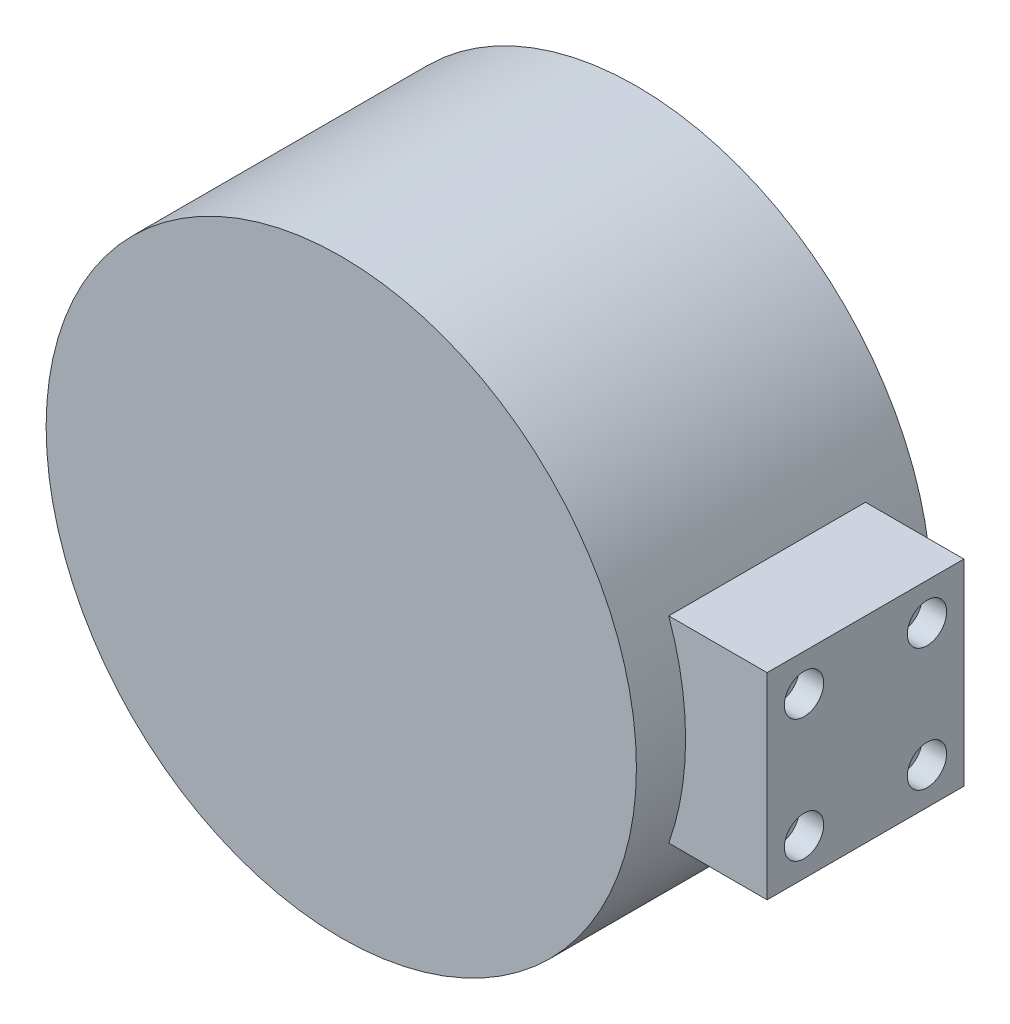
from build123d import *

# Parameters (mm, degrees)
EXTRUDE_1_DEPTH     = 60
CUT_EXTRUDE_1_DEPTH = 10
CUT_EXTRUDE_2_DEPTH = 10
SKETCH_4_R          = 40
CUT_EXTRUDE_3_DEPTH = 20
SKETCH_5_R          = 4
CUT_EXTRUDE_4_DEPTH = 5


with BuildPart() as part:
    # 草图1 → 凸台-拉伸1 (new body)
    with BuildSketch(Plane.XY):
        with BuildLine():
            Line((56.568542495, -20), (76.568542495, -20))
            Line((76.568542495, -20), (76.568542495, 20))
            Line((76.568542495, 20), (56.568542495, 20))
            ThreePointArc((56.568542495, 20), (-60, 0), (56.568542495, -20))
        make_face()
    extrude(amount=EXTRUDE_1_DEPTH)

    # 草图2 → 切除-拉伸1 (cut)
    with BuildSketch(Plane(origin=(0, 0, 0), x_dir=(-1, 0, 0), z_dir=(0, 0, -1))):
        with BuildLine():
            Line((-76.568542495, 20), (-76.568542495, -20))
            Line((-76.568542495, -20), (-56.568542495, -20))
            ThreePointArc((-56.568542495, -20), (-60, 0), (-56.568542495, 20))
            Line((-56.568542495, 20), (-76.568542495, 20))
        make_face()
    extrude(amount=-CUT_EXTRUDE_1_DEPTH, mode=Mode.SUBTRACT)

    # 草图3 → 切除-拉伸2 (cut)
    with BuildSketch(Plane.XY.offset(60)):
        with BuildLine():
            Line((76.568542495, 20), (76.568542495, -20))
            Line((76.568542495, -20), (56.568542495, -20))
            ThreePointArc((56.568542495, -20), (60, 0), (56.568542495, 20))
            Line((56.568542495, 20), (76.568542495, 20))
        make_face()
    extrude(amount=-CUT_EXTRUDE_2_DEPTH, mode=Mode.SUBTRACT)

    # 草图4 → 切除-拉伸3 (cut)
    with BuildSketch(Plane(origin=(0, 0, 0), x_dir=(-1, 0, 0), z_dir=(0, 0, -1))):
        Circle(SKETCH_4_R)
    extrude(amount=-CUT_EXTRUDE_3_DEPTH, mode=Mode.SUBTRACT)

    # 草图5 → 切除-拉伸4 (cut)
    with BuildSketch(Plane(origin=(76.568542495, 0, 0), x_dir=(0, 0, -1), z_dir=(1, 0, 0))):
        with Locations((-17.5, 12.5)):
            Circle(SKETCH_5_R)
        with Locations((-17.5, -12.5)):
            Circle(SKETCH_5_R)
        with Locations((-42.5, -12.5)):
            Circle(SKETCH_5_R)
        with Locations((-42.5, 12.5)):
            Circle(SKETCH_5_R)
    extrude(amount=-CUT_EXTRUDE_4_DEPTH, mode=Mode.SUBTRACT)


solid = part.part
